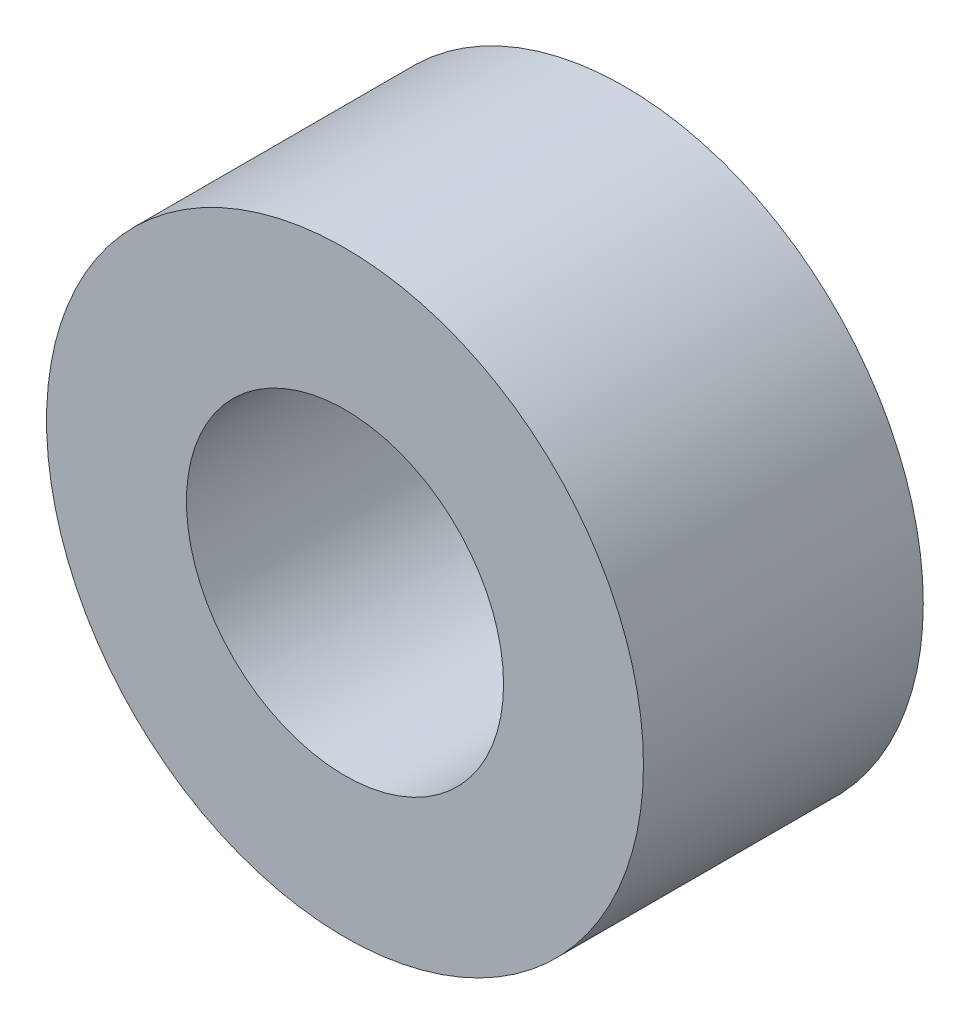
from build123d import *

# Parameters (mm, degrees)
ESQUISSE1_R        = 3.2
ESQUISSE1_R_2      = 1.7
BOSS_EXTRU_1_DEPTH = 3


with BuildPart() as part:
    # Esquisse1 → Boss.-Extru.1 (new body)
    with BuildSketch(Plane.XY):
        with Locations((-30.301926647, 53.599979038)):
            Circle(ESQUISSE1_R)
        with Locations((-30.301926647, 53.599979038)):
            Circle(ESQUISSE1_R_2, mode=Mode.SUBTRACT)
    extrude(amount=BOSS_EXTRU_1_DEPTH)


solid = part.part
